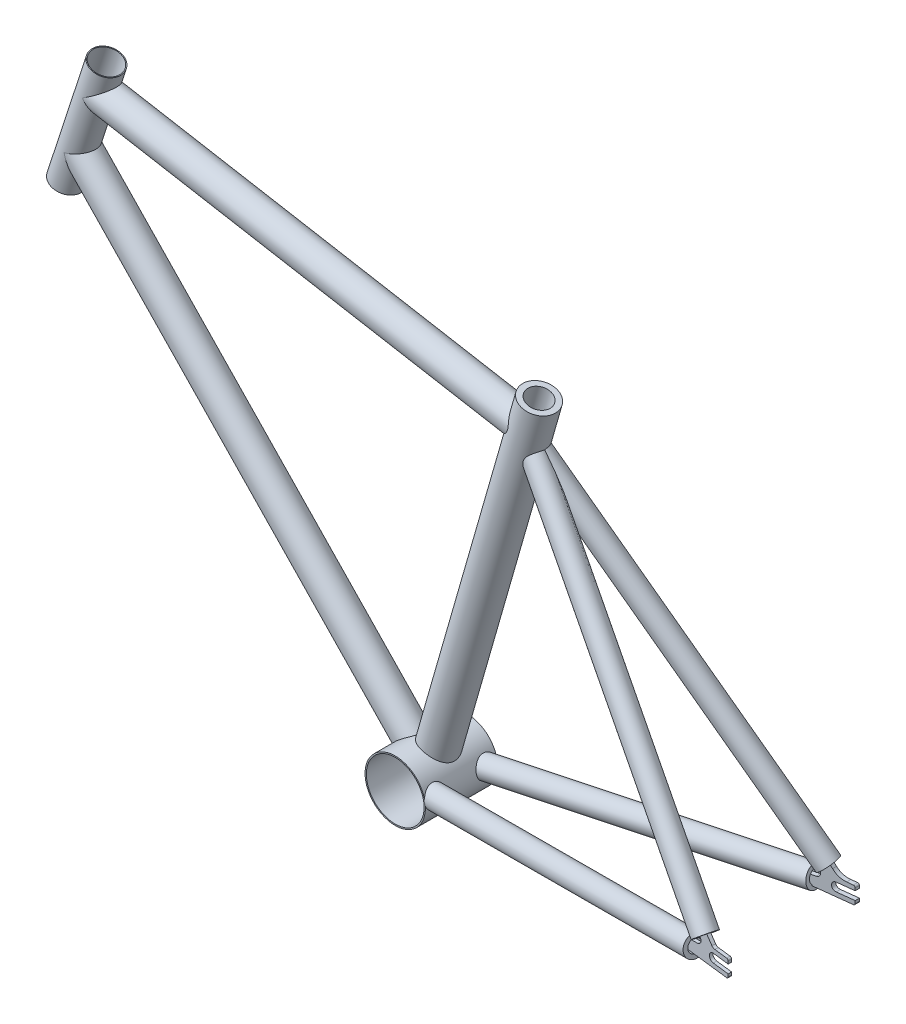
from build123d import *
from build123d.topology import SkipClean

# Parameters (mm, degrees)
SKETCH3_R                 = 17.5
SKETCH3_R_2               = 16.5
BOSS_EXTRUDE1_DEPTH       = 150
SKETCH5_R                 = 35.5
SKETCH5_R_2               = 34
BOSS_EXTRUDE2_DEPTH       = 42.5
BOSS_EXTRUDE3_REACH       = 748.603
BOSS_EXTRUDE3_END_RADIUS  = 35.5
SKETCH4_R                 = 20
SKETCH4_R_2               = 13.6
BOSS_EXTRUDE5_REACH       = 579.895
BOSS_EXTRUDE5_END_RADIUS  = 20
SKETCH6_R                 = 17.5
SKETCH6_R_2               = 10
BOSS_EXTRUDE6_REACH       = 579.895
BOSS_EXTRUDE6_END_RADIUS  = 17.5
SKETCH7_R                 = 17.5
SKETCH7_R_2               = 10
BOSS_EXTRUDE7_REACH       = 481.041
BOSS_EXTRUDE7_END_RADIUS  = 17.5
SKETCH8_R                 = 17.5
SKETCH8_R_2               = 10
BOSS_EXTRUDE8_REACH       = 481.041
SKETCH9_R                 = 17.5
SKETCH9_R_2               = 10
BOSS_EXTRUDE9_DEPTH       = 2
BOSS_EXTRUDE10_REACH      = 968.967
BOSS_EXTRUDE10_END_RADIUS = 35.5
SKETCH13_R                = 12.5
SKETCH13_R_2              = 7.5
BOSS_EXTRUDE11_REACH      = 971.726
BOSS_EXTRUDE11_END_RADIUS = 20
SKETCH14_R                = 12.5
SKETCH14_R_2              = 7.5
BOSS_EXTRUDE12_DEPTH      = 5
CUT_EXTRUDE2_DEPTH        = 100


with BuildPart() as part:
    # Sketch3 → Boss-Extrude1 (new body)
    with BuildSketch(Plane(origin=(186.089511011, 480.394118363, 0), x_dir=(0.9510565162951544, -0.3090169943749449, 0), z_dir=(0.3090169943749449, 0.9510565162951544, 0))):
        with Locations(Location((0, 0, 0), (0, 0, 180))):
            Circle(SKETCH3_R)
        with Locations(Location((0, 0, 0), (0, 0, 180))):
            Circle(SKETCH3_R_2, mode=Mode.SUBTRACT)
    extrude(amount=-BOSS_EXTRUDE1_DEPTH)



with BuildPart() as body_2:
    # Sketch5 → Boss-Extrude2 (new, symmetric)
    with BuildSketch(Plane.XY):
        with Locations((568.516821033, -50)):
            Circle(SKETCH5_R)
        with Locations((568.516821033, -50)):
            Circle(SKETCH5_R_2, mode=Mode.SUBTRACT)
    extrude(amount=BOSS_EXTRUDE2_DEPTH, both=True)

    # Sketch9 → Boss-Extrude8 (add, up to next)
    with BuildSketch(Plane(origin=(361.079773817, 165.266592076, 0), x_dir=(0.7200806808230846, 0.6938903466005008, 0), z_dir=(-0.6938903466005008, 0.7200806808230846, 0)), mode=Mode.PRIVATE) as boss_extrude8_sk1:
        with Locations(Location((0, 0, 0), (0, 0, 270))):
            Circle(SKETCH9_R)
        with Locations(Location((0, 0, 0), (0, 0, 180))):
            Circle(SKETCH9_R_2, mode=Mode.SUBTRACT)
    boss_extrude8_tool1 = extrude(boss_extrude8_sk1.sketch, amount=-BOSS_EXTRUDE8_REACH, mode=Mode.PRIVATE) - body_2.part


with BuildPart() as body_3:
    # Boss-Extrude3: up to this cylinder (the profile starts outside it)
    boss_extrude3_end = Plane(origin=(568.516821033, -50, 0), z_dir=(0, 0, -1)) * Cylinder(BOSS_EXTRUDE3_END_RADIUS, 1569.206, mode=Mode.PRIVATE)
    # Sketch4 → Boss-Extrude3 (new, up to the surface)
    with BuildSketch(Plane(origin=(695.310004709, 392.180380132, 0), x_dir=(0.9612616959383199, -0.2756373558169958, 0), z_dir=(0.2756373558169958, 0.96126169593832, 0)), mode=Mode.PRIVATE) as boss_extrude3_sk1:
        with Locations(Location((0, 0, 0), (0, 0, 180))):
            Circle(SKETCH4_R)
        with Locations(Location((0, 0, 0), (0, 0, 180))):
            Circle(SKETCH4_R_2, mode=Mode.SUBTRACT)
    boss_extrude3_tool1 = extrude(boss_extrude3_sk1.sketch, amount=-BOSS_EXTRUDE3_REACH, mode=Mode.PRIVATE) - boss_extrude3_end
    add(boss_extrude3_tool1.solids().sort_by_distance((713.991467, 386.823557, 0))[0])

    # Boss-Extrude5: up to this cylinder (the profile starts outside it)
    boss_extrude5_end = Plane(origin=(673.151986164, 314.90618621, 0), z_dir=(0.2756373558169958, 0.9612616959383199, 0)) * Cylinder(BOSS_EXTRUDE5_END_RADIUS, 1200.79, mode=Mode.PRIVATE)
    # Sketch6 → Boss-Extrude5 (add, up to the surface)
    with BuildSketch(Plane(origin=(430.273916208, 402.143760212, 0), x_dir=(0, 0, -1), z_dir=(0.9848077530122081, -0.17364817766693064, 0)), mode=Mode.PRIVATE) as boss_extrude5_sk1:
        with Locations(Location((0, 0, 0), (0, 0, 90))):
            Circle(SKETCH6_R)
        with Locations(Location((0, 0, 0), (0, 0, 270))):
            Circle(SKETCH6_R_2, mode=Mode.SUBTRACT)
    boss_extrude5_tool1 = extrude(boss_extrude5_sk1.sketch, amount=BOSS_EXTRUDE5_REACH, mode=Mode.PRIVATE) - boss_extrude5_end
    add(boss_extrude5_tool1.solids().sort_by_distance((427.321025, 385.39708, 0))[0])


with BuildPart() as part_1:
    with SkipClean():  # the faces are left unmerged after this step: merging them gives an invalid solid
        add(part.part)

        add(body_3.part)  # Boss-Extrude6 merges body 3
        # Boss-Extrude6: up to this cylinder (the profile starts outside it)
        boss_extrude6_end = Plane(origin=(186.40984349, 481.380000362, 0), z_dir=(0.3090169943749449, 0.9510565162951544, 0)) * Cylinder(BOSS_EXTRUDE6_END_RADIUS, 1195.79, mode=Mode.PRIVATE)
        # Sketch7 → Boss-Extrude6 (add, up to the surface)
        with BuildSketch(Plane(origin=(430.273916208, 402.143760212, 0), x_dir=(0, 0, -1), z_dir=(0.9848077530122081, -0.17364817766693064, 0)), mode=Mode.PRIVATE) as boss_extrude6_sk1:
            Circle(SKETCH7_R)
            with Locations(Location((0, 0, 0), (0, 0, 90))):
                Circle(SKETCH7_R_2, mode=Mode.SUBTRACT)
        boss_extrude6_tool1 = extrude(boss_extrude6_sk1.sketch, amount=-BOSS_EXTRUDE6_REACH, mode=Mode.PRIVATE) - boss_extrude6_end
        add(boss_extrude6_tool1.solids().sort_by_distance((430.273916, 402.14376, 17.005025))[0])

    # Boss-Extrude7: up to this cylinder (the profile starts outside it)
    with SkipClean():  # the faces are left unmerged after this step: merging them gives an invalid solid
        boss_extrude7_end = Plane(origin=(110.185937907, 246.78694101, 0), z_dir=(0.3090169943749449, 0.9510565162951544, 0)) * Cylinder(BOSS_EXTRUDE7_END_RADIUS, 998.082, mode=Mode.PRIVATE)
        # Sketch8 → Boss-Extrude7 (add, up to the surface)
        with BuildSketch(Plane(origin=(361.079773817, 165.266592076, 0), x_dir=(0.7200806808230846, 0.6938903466005008, 0), z_dir=(-0.6938903466005008, 0.7200806808230846, 0)), mode=Mode.PRIVATE) as boss_extrude7_sk1:
            with Locations(Location((0, 0, 0), (0, 0, 270))):
                Circle(SKETCH8_R)
            Circle(SKETCH8_R_2, mode=Mode.SUBTRACT)
        boss_extrude7_tool1 = extrude(boss_extrude7_sk1.sketch, amount=BOSS_EXTRUDE7_REACH, mode=Mode.PRIVATE) - boss_extrude7_end
        add(boss_extrude7_tool1.solids().sort_by_distance((361.079774, 165.266592, -17.005025))[0])


with BuildPart() as body_2_1:
    add(body_2.part)

    add(part_1.part)  # Boss-Extrude8 merges part
    add(boss_extrude8_tool1.solids().sort_by_distance((361.079774, 165.266592, -17.005025))[0])

    # Boss-Extrude10: up to this cylinder (the profile starts outside it)
    with SkipClean():  # the faces are left unmerged after this step: merging them gives an invalid solid
        boss_extrude10_end = Plane(origin=(568.516821033, -50, 70.785807), z_dir=(0, 0, -1)) * Cylinder(BOSS_EXTRUDE10_END_RADIUS, 2009.934, mode=Mode.PRIVATE)
        # Sketch13 → Boss-Extrude10 (add, up to the surface)
        with BuildSketch(Plane(origin=(949.497551763, -3.327673182, 70.785807384), x_dir=(0.11450094690836618, 0.014038813850558178, -0.9933239375263022), z_dir=(0.9863391248066026, 0.11759133559513817, 0.11535774212725007)), mode=Mode.PRIVATE) as boss_extrude10_sk1:
            with Locations(Location((0, 0, 0), (0, 0, 89.977924838))):
                Circle(SKETCH13_R)
            with Locations(Location((0, 0, 0), (0, 0, 89.977924838))):
                Circle(SKETCH13_R_2, mode=Mode.SUBTRACT)
        boss_extrude10_tool1 = extrude(boss_extrude10_sk1.sketch, amount=-BOSS_EXTRUDE10_REACH, mode=Mode.PRIVATE) - boss_extrude10_end
        boss_extrude10 = boss_extrude10_tool1.solids().sort_by_distance((950.935468, -15.388708, 70.785807))[0]
        add(boss_extrude10)



with BuildPart() as body_2_2:
    # Sketch11 → Boss-Extrude9 (new, symmetric)
    with BuildSketch(Plane(origin=(4.645447479, 0, -39.71980134), x_dir=(-0.9932300841439066, 0, -0.11616367741892569), z_dir=(0.11616367741892569, 0, -0.9932300841439066))):
        with BuildLine():
            Line((-996.521458751, -10), (-952.097739753, -10))
            ThreePointArc((-952.097739753, -10), (-946.094540772, -10.180354629), (-940.112995886, -10.72076796))
            Line((-940.112995886, -10.72076796), (-892.443818335, -16.475273425))
            Line((-892.443818335, -16.475273425), (-891.005649071, -4.56176558))
            Line((-891.005649071, -4.56176558), (-957.579229, 3.474832683))
            ThreePointArc((-957.579229, 3.474832683), (-961.644992026, 6.639413015), (-960.757458256, 11.714576211))
            Line((-960.757458256, 11.714576211), (-921.448075144, 57.044173599))
            Line((-921.448075144, 57.044173599), (-930.513994622, 64.906050222))
            Line((-930.513994622, 64.906050222), (-976.632758849, 11.724218074))
            ThreePointArc((-976.632758849, 11.724218074), (-978.33404005, 10.451433763), (-980.410225298, 10))
            Line((-980.410225298, 10), (-996.521458751, 10))
            ThreePointArc((-996.521458751, 10), (-997.935672314, 9.414213562), (-998.521458751, 8))
            Line((-998.521458751, 8), (-998.521458751, -8))
            ThreePointArc((-998.521458751, -8), (-997.935672314, -9.414213562), (-996.521458751, -10))
        make_face()
    extrude(amount=BOSS_EXTRUDE9_DEPTH, both=True)


with BuildPart() as body_2_3:
    with SkipClean():  # the faces are left unmerged after this step: merging them gives an invalid solid
        add(body_2_1.part)

        add(body_2_2.part)  # Boss-Extrude11 merges body 2 2
        # Boss-Extrude11: up to this cylinder (the profile starts outside it)
        boss_extrude11_end = Plane(origin=(613.127080419, 105.574462927, 0), z_dir=(0.2756373558169958, 0.9612616959383199, 0)) * Cylinder(BOSS_EXTRUDE11_END_RADIUS, 1984.452, mode=Mode.PRIVATE)
        # Sketch14 → Boss-Extrude11 (add, up to the surface)
        with BuildSketch(Plane(origin=(963.400930566, 15.645514522, 72.411883392), x_dir=(-0.7702241938496818, -0.623119435994589, 0.13592961301494794), z_dir=(0.6377732160746, -0.7524847689091817, 0.16435327017603568)), mode=Mode.PRIVATE) as boss_extrude11_sk1:
            with Locations(Location((0, 0, 0), (0, 0, 187.920765774))):
                Circle(SKETCH14_R)
            with Locations(Location((0, 0, 0), (0, 0, 187.920765774))):
                Circle(SKETCH14_R_2, mode=Mode.SUBTRACT)
        boss_extrude11_tool1 = extrude(boss_extrude11_sk1.sketch, amount=-BOSS_EXTRUDE11_REACH, mode=Mode.PRIVATE) - boss_extrude11_end
        boss_extrude11 = boss_extrude11_tool1.solids().sort_by_distance((954.134911, 7.792041, 72.411883))[0]
        add(boss_extrude11)

    # Mirror5: Boss-Extrude10 across plane
    with SkipClean():  # the faces are left unmerged after this step: merging them gives an invalid solid
        add(boss_extrude10.mirror(Plane.XY))

    # Mirror7: Boss-Extrude11 across plane
    with SkipClean():  # the faces are left unmerged after this step: merging them gives an invalid solid
        add(boss_extrude11.mirror(Plane.XY))

    # Sketch17 → Boss-Extrude12 (add)
    with SkipClean():  # the faces are left unmerged after this step: merging them gives an invalid solid
        with BuildSketch(Plane(origin=(4.645447479, 0, 39.71980134), x_dir=(0.9932300841439066, 0, -0.11616367741892569), z_dir=(0.11616367741892569, 0, 0.9932300841439066))):
            with BuildLine():
                Line((1007.407705718, 8.005485562), (1007.407705718, -8.001206159))
                ThreePointArc((1007.407705718, -8.001206159), (1006.82191928, -9.415419721), (1005.407705718, -10.001206159))
                Line((1005.407705718, -10.001206159), (950.321842168, -10.001206159))
                ThreePointArc((950.321842168, -10.001206159), (943.816212161, -10.21304665), (937.338145271, -10.847670595))
                Line((937.338145271, -10.847670595), (890.72122517, -16.951940678))
                Line((890.72122517, -16.951940678), (889.494321115, -5.172232911))
                Line((889.494321115, -5.172232911), (956.609193825, 1.818051662))
                ThreePointArc((956.609193825, 1.818051662), (960.741354271, 4.953678272), (959.868692013, 10.066932107))
                Line((959.868692013, 10.066932107), (923.15387266, 52.404609469))
                Line((923.15387266, 52.404609469), (934.486272007, 62.231955247))
                Line((934.486272007, 62.231955247), (973.795655119, 16.902357858))
                ThreePointArc((973.795655119, 16.902357858), (980.600779922, 11.811220613), (988.905520915, 10.005485562))
                Line((988.905520915, 10.005485562), (1005.407705718, 10.005485562))
                ThreePointArc((1005.407705718, 10.005485562), (1006.82191928, 9.419699125), (1007.407705718, 8.005485562))
            make_face()
        extrude(amount=BOSS_EXTRUDE12_DEPTH)

    # Sketch19 → Cut-Extrude2 (cut, symmetric)
    with SkipClean():  # the faces are left unmerged after this step: merging them gives an invalid solid
        with BuildSketch(Plane.XY):
            with BuildLine():
                Line((976.174672619, 5), (996.174672619, 5))
                Line((996.174672619, 5), (996.174672619, 8))
                add(Edge.make_bspline(
                    [(996.174672619, 8), (996.174672619, 10), (994.188212451, 10)],
                    knots=[1.570796327, 1.570796327, 1.570796327, 3.141592654, 3.141592654, 3.141592654], degree=2, weights=[1, 0.707106781, 1]))
                Line((994.188212451, 10), (994.188212451, 11.330169166))
                Line((994.188212451, 11.330169166), (1011.989837281, 11.330169166))
                Line((1011.989837281, 11.330169166), (1011.989837281, 10))
                Line((1011.989837281, 10), (1011.989837281, 5))
                Line((1011.989837281, 5), (1011.989837281, -5))
                Line((1011.989837281, -5), (1011.989837281, -10))
                Line((1011.989837281, -10), (1011.989837281, -11.181834584))
                Line((1011.989837281, -11.181834584), (994.188212451, -11.181834584))
                Line((994.188212451, -11.181834584), (994.188212451, -10))
                add(Edge.make_bspline(
                    [(994.188212451, -10), (996.174672619, -10), (996.174672619, -8)],
                    knots=[0, 0, 0, 1.570796327, 1.570796327, 1.570796327], degree=2, weights=[1, 0.707106781, 1]))
                Line((996.174672619, -8), (996.174672619, -5))
                Line((996.174672619, -5), (976.174672619, -5))
                ThreePointArc((976.174672619, -5), (971.174672619, 0), (976.174672619, 5))
            make_face()
        extrude(amount=CUT_EXTRUDE2_DEPTH, both=True, mode=Mode.SUBTRACT)


solid = body_2_3.part
